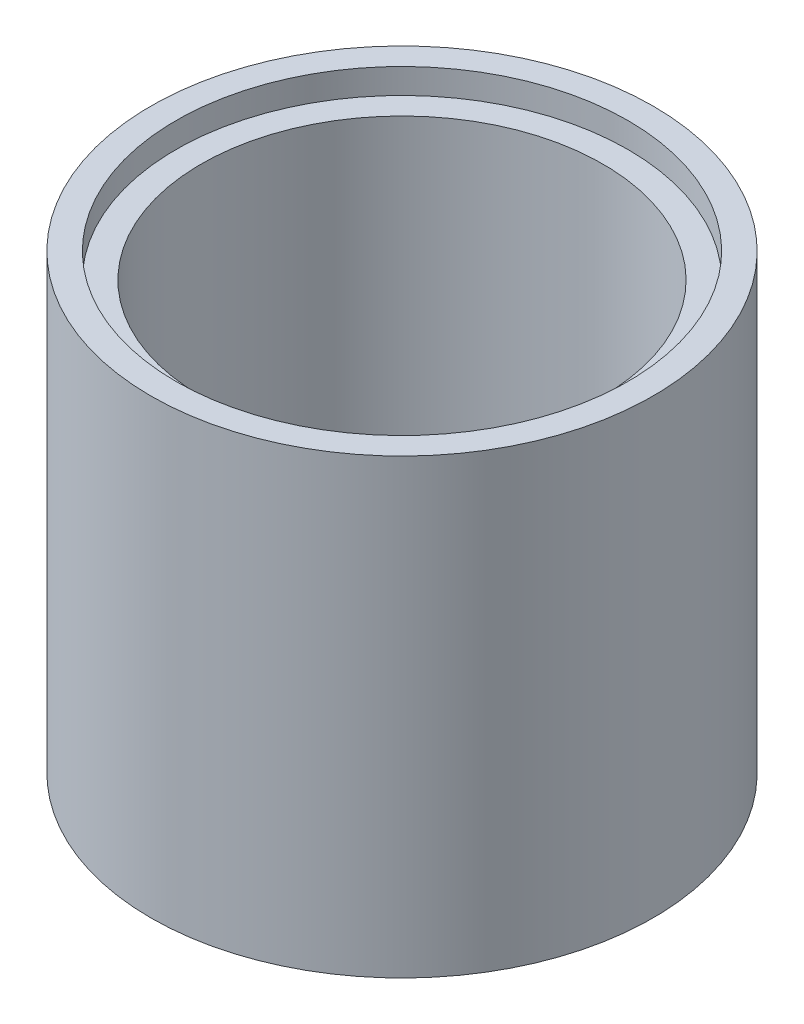
from build123d import *

# Parameters (mm, degrees)
CROQUIS1_R              = 25
SALIENTE_EXTRUIR1_DEPTH = 45
CROQUIS2_R              = 20
CORTAR_EXTRUIR1_DEPTH   = 40
CROQUIS3_R              = 22.5
CORTAR_EXTRUIR2_DEPTH   = 2.5


with BuildPart() as part:
    # Croquis1 → Saliente-Extruir1 (new body)
    with BuildSketch(Plane(origin=(0, 0, 0), x_dir=(1, 0, 0), z_dir=(0, 1, 0))):
        Circle(CROQUIS1_R)
    extrude(amount=SALIENTE_EXTRUIR1_DEPTH)

    # Croquis2 → Cortar-Extruir1 (cut)
    with BuildSketch(Plane(origin=(0, 45, 0), x_dir=(1, 0, 0), z_dir=(0, 1, 0))):
        Circle(CROQUIS2_R)
    extrude(amount=-CORTAR_EXTRUIR1_DEPTH, mode=Mode.SUBTRACT)

    # Croquis3 → Cortar-Extruir2 (cut)
    with BuildSketch(Plane(origin=(0, 45, 0), x_dir=(1, 0, 0), z_dir=(0, 1, 0))):
        Circle(CROQUIS3_R)
    extrude(amount=-CORTAR_EXTRUIR2_DEPTH, mode=Mode.SUBTRACT)


solid = part.part
